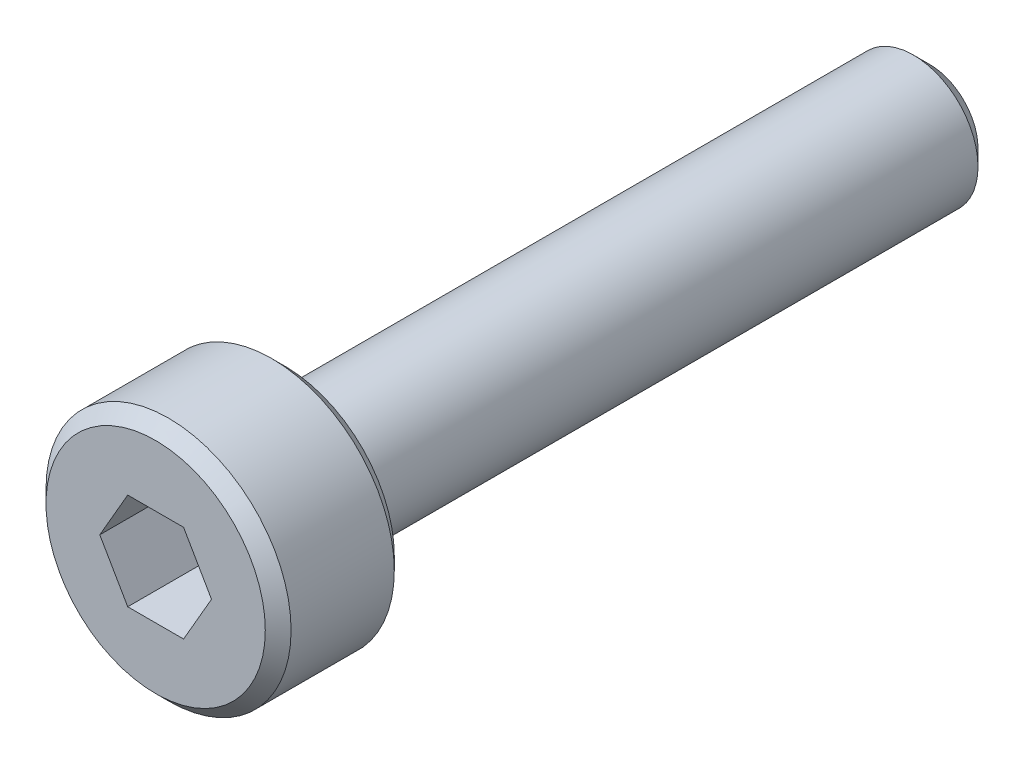
from build123d import *

# Parameters (mm, degrees)
CUT_EXTRUDE_1_DEPTH = 1.8


with BuildPart() as part:
    # Эскиз1 → Повернуть1 (revolve)
    with BuildSketch(Plane(origin=(0, 0, 0), x_dir=(1, 0, 0), z_dir=(0, 1, 0))):
        Polygon((0, 0), (1.7, 0), (1.9, 0.2), (1.9, 1.8), (1.7, 2), (1, 2), (1, 11.75), (0.75, 12), (0, 12), align=None)
    revolve(axis=Axis((0, 0, 0), (0, 0, -1)))

    # Эскиз2 → Вырез-Вытянуть1 (cut)
    with BuildSketch(Plane.XY):
        Polygon((0.866025404, 0), (0.433012702, 0.75), (-0.433012702, 0.75), (-0.866025404, 0), (-0.433012702, -0.75), (0.433012702, -0.75), align=None)
    extrude(amount=-CUT_EXTRUDE_1_DEPTH, mode=Mode.SUBTRACT)


solid = part.part
